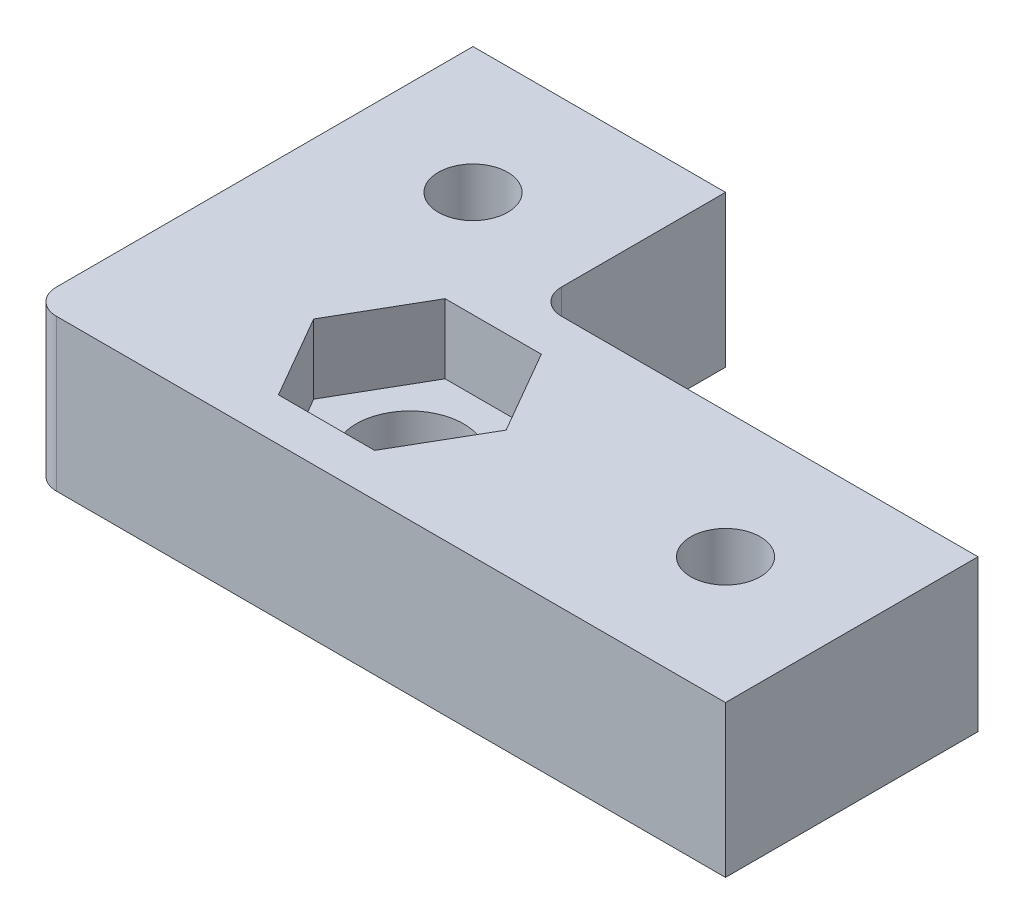
from build123d import *

# Parameters (mm, degrees)
SALIENTE_EXTRUIR1_DEPTH = 12
SALIENTE_EXTRUIR2_DEPTH = 38
CROQUIS8_W              = 40
CROQUIS8_H              = 20
CORTAR_EXTRUIR5_DEPTH   = 20
CROQUIS3_R              = 4.25
CORTAR_EXTRUIR1_DEPTH   = 13
CORTAR_EXTRUIR2_DEPTH   = 5.5
REDONDEO1_R             = 2
CROQUIS5_W              = 4.8
CROQUIS5_H              = 35
CROQUIS5_W_2            = 15
CROQUIS5_H_2            = 4.8
SALIENTE_EXTRUIR3_DEPTH = 1
NGULO_DE_SALIDA1_ANGLE  = 15
NGULO_DE_SALIDA2_ANGLE  = 15
REDONDEO2_R             = 2
NGULO_DE_SALIDA3_ANGLE  = 15
REDONDEO3_R             = 1
CORTAR_EXTRUIR4_DEPTH   = 66
CORTAR_EXTRUIR6_DEPTH   = 66
CROQUIS12_W             = 65
CROQUIS12_H             = 38
CORTAR_EXTRUIR9_DEPTH   = 66
CROQUIS13_OUTSIDE_W     = 85.54
CROQUIS13_OUTSIDE_H     = 85.54
CROQUIS13_OUTSIDE_W_2   = 55
CROQUIS13_OUTSIDE_H_2   = 35
CORTAR_EXTRUIR10_DEPTH  = 13
REDONDEO5_R             = 2
CROQUIS14_R             = 2.75
CORTAR_EXTRUIR11_DEPTH  = 13


with BuildPart() as part:
    # Croquis1 → Saliente-Extruir1 (new body)
    with BuildSketch(Plane(origin=(0, 0, 0), x_dir=(1, 0, 0), z_dir=(0, 1, 0))):
        Polygon((25, 65), (25, 25), (65, 25), (65, 0), (0, 0), (0, 65), align=None)
    extrude(amount=SALIENTE_EXTRUIR1_DEPTH)

    # Croquis2 → Saliente-Extruir2 (add)
    with BuildSketch(Plane(origin=(0, 12, 0), x_dir=(1, 0, 0), z_dir=(0, 1, 0))):
        Polygon((0, 65), (0, 0), (65, 0), (65, 5), (37.4, 5), (37.4, 6), (32.6, 6), (32.6, 5), (17.4, 5), (17.4, 6), (12.6, 6), (12.6, 5), (5, 5), (5, 12.6), (6, 12.6), (6, 17.4), (5, 17.4), (5, 65), align=None)
    extrude(amount=SALIENTE_EXTRUIR2_DEPTH)

    # Croquis8 → Cortar-Extruir5 (cut)
    with BuildSketch(Plane(origin=(0, 50, 0), x_dir=(1, 0, 0), z_dir=(0, 1, 0))):
        with Locations((25, 15)):
            Rectangle(CROQUIS8_W, CROQUIS8_H)
    extrude(amount=-CORTAR_EXTRUIR5_DEPTH, mode=Mode.SUBTRACT)

    # Croquis3 → Cortar-Extruir1 (cut, through all)
    with BuildSketch(Plane(origin=(0, 12, 0), x_dir=(1, 0, 0), z_dir=(0, 1, 0))):
        with Locations((25, 15)):
            Circle(CROQUIS3_R)
    extrude(amount=-CORTAR_EXTRUIR1_DEPTH, mode=Mode.SUBTRACT)

    # Croquis4 → Cortar-Extruir2 (cut)
    with BuildSketch(Plane(origin=(0, 12, 0), x_dir=(1, 0, 0), z_dir=(0, 1, 0))):
        Polygon((32.621023553, 15), (28.810511777, 21.6), (21.189488223, 21.6), (17.378976447, 15), (21.189488223, 8.4), (28.810511777, 8.4), align=None)
    extrude(amount=-CORTAR_EXTRUIR2_DEPTH, mode=Mode.SUBTRACT)

    # Redondeo1
    redondeo1_edges = [part.edges().sort_by_distance(p)[0] for p in [
        (25, 6, -25),
    ]]
    fillet(redondeo1_edges, radius=REDONDEO1_R)

    # Croquis5 → Saliente-Extruir3 (add)
    with BuildSketch(Plane(origin=(0, 12, 0), x_dir=(1, 0, 0), z_dir=(0, 1, 0))):
        with Locations((15, 47.5)):
            Rectangle(CROQUIS5_W, CROQUIS5_H)
        with Locations((57.5, 15)):
            Rectangle(CROQUIS5_W_2, CROQUIS5_H_2)
    extrude(amount=SALIENTE_EXTRUIR3_DEPTH)

    # Ángulo de salida1
    ngulo_de_salida1_faces = [part.faces().sort_by_distance(p)[0] for p in [
        (57.5, 12.5, -17.4),
        (50, 12.5, -15),
        (57.5, 12.5, -12.6),
        (12.6, 12.5, -47.5),
        (15, 12.5, -30),
        (17.4, 12.5, -47.5),
    ]]
    draft(ngulo_de_salida1_faces, Plane.ZX.offset(12), NGULO_DE_SALIDA1_ANGLE)

    # Ángulo de salida2
    ngulo_de_salida2_faces = [part.faces().sort_by_distance(p)[0] for p in [
        (15, 30, -5.5),
        (35, 30, -5.5),
        (37.4, 21, -5.5),
        (32.6, 21, -5.5),
        (17.4, 21, -5.5),
        (12.6, 21, -5.5),
    ]]
    draft(ngulo_de_salida2_faces, Plane(origin=(65, 50, -5), x_dir=(-1, 0, 0), z_dir=(0, 0, -1)), NGULO_DE_SALIDA2_ANGLE)

    # Redondeo2
    redondeo2_edges = [part.edges().sort_by_distance(p)[0] for p in [
        (0, 25, 0),
    ]]
    fillet(redondeo2_edges, radius=REDONDEO2_R)

    # Ángulo de salida3
    ngulo_de_salida3_faces = [part.faces().sort_by_distance(p)[0] for p in [
        (5.5, 30, -15),
        (5.5, 21, -17.4),
        (5.5, 21, -12.6),
    ]]
    draft(ngulo_de_salida3_faces, Plane(origin=(5, 50, -5), x_dir=(0, 0, 1), z_dir=(1, 0, 0)), NGULO_DE_SALIDA3_ANGLE)

    # Redondeo3
    redondeo3_edges = [part.edges().sort_by_distance(p)[0] for p in [
        (5, 31, -5),
    ]]
    fillet(redondeo3_edges, radius=REDONDEO3_R)

    # Croquis6 → Cortar-Extruir4 (cut, through all)
    with BuildSketch(Plane.ZY):
        with BuildLine():
            Line((-16, 45.5), (-14, 45.5))
            Line((-14, 45.5), (-12.696855696, 43.502673056))
            ThreePointArc((-12.696855696, 43.502673056), (-15, 39.25), (-17.303144304, 43.502673056))
            Line((-17.303144304, 43.502673056), (-16, 45.5))
        make_face()
        with BuildLine():
            Line((-56, 45.5), (-54, 45.5))
            Line((-54, 45.5), (-52.696855696, 43.502673056))
            ThreePointArc((-52.696855696, 43.502673056), (-55, 39.25), (-57.303144304, 43.502673056))
            Line((-57.303144304, 43.502673056), (-56, 45.5))
        make_face()
        with BuildLine():
            Line((-56, 25.5), (-54, 25.5))
            Line((-54, 25.5), (-52.696855696, 23.502673056))
            ThreePointArc((-52.696855696, 23.502673056), (-55, 19.25), (-57.303144304, 23.502673056))
            Line((-57.303144304, 23.502673056), (-56, 25.5))
        make_face()
    extrude(amount=-CORTAR_EXTRUIR4_DEPTH, mode=Mode.SUBTRACT)

    # Croquis9 → Cortar-Extruir6 (cut, through all)
    with BuildSketch(Plane.XY):
        with BuildLine():
            Line((14, 45.5), (16, 45.5))
            Line((16, 45.5), (17.303144304, 43.502673056))
            ThreePointArc((17.303144304, 43.502673056), (15, 39.25), (12.696855696, 43.502673056))
            Line((12.696855696, 43.502673056), (14, 45.5))
        make_face()
        with BuildLine():
            Line((54, 45.5), (56, 45.5))
            Line((56, 45.5), (57.303144304, 43.502673056))
            ThreePointArc((57.303144304, 43.502673056), (55, 39.25), (52.696855696, 43.502673056))
            Line((52.696855696, 43.502673056), (54, 45.5))
        make_face()
        with BuildLine():
            Line((54, 25.5), (56, 25.5))
            Line((56, 25.5), (57.303144304, 23.502673056))
            ThreePointArc((57.303144304, 23.502673056), (55, 19.25), (52.696855696, 23.502673056))
            Line((52.696855696, 23.502673056), (54, 25.5))
        make_face()
    extrude(amount=-CORTAR_EXTRUIR6_DEPTH, mode=Mode.SUBTRACT)

    # Croquis12 → Cortar-Extruir9 (cut, through all)
    with BuildSketch(Plane(origin=(65, 0, 0), x_dir=(0, 0, -1), z_dir=(1, 0, 0))):
        with Locations((32.5, 31)):
            Rectangle(CROQUIS12_W, CROQUIS12_H)
    extrude(amount=-CORTAR_EXTRUIR9_DEPTH, mode=Mode.SUBTRACT)

    # Croquis13 outside → Cortar-Extruir10 (cut, through all)
    with BuildSketch(Plane(origin=(0, 12, 0), x_dir=(1, 0, 0), z_dir=(0, 1, 0))):
        with Locations((32.5, 32.5)):
            Rectangle(CROQUIS13_OUTSIDE_W, CROQUIS13_OUTSIDE_H)
        with Locations((32.5, 22.5)):
            Rectangle(CROQUIS13_OUTSIDE_W_2, CROQUIS13_OUTSIDE_H_2, mode=Mode.SUBTRACT)
    extrude(amount=-CORTAR_EXTRUIR10_DEPTH, mode=Mode.SUBTRACT)

    # Redondeo5
    redondeo5_edges = [part.edges().sort_by_distance(p)[0] for p in [
        (5, 6, -5),
    ]]
    fillet(redondeo5_edges, radius=REDONDEO5_R)

    # Croquis14 → Cortar-Extruir11 (cut, through all)
    with BuildSketch(Plane(origin=(0, 12, 0), x_dir=(1, 0, 0), z_dir=(0, 1, 0))):
        with Locations((15, 30)):
            Circle(CROQUIS14_R)
        with Locations((50, 15)):
            Circle(CROQUIS14_R)
    extrude(amount=-CORTAR_EXTRUIR11_DEPTH, mode=Mode.SUBTRACT)


solid = part.part
